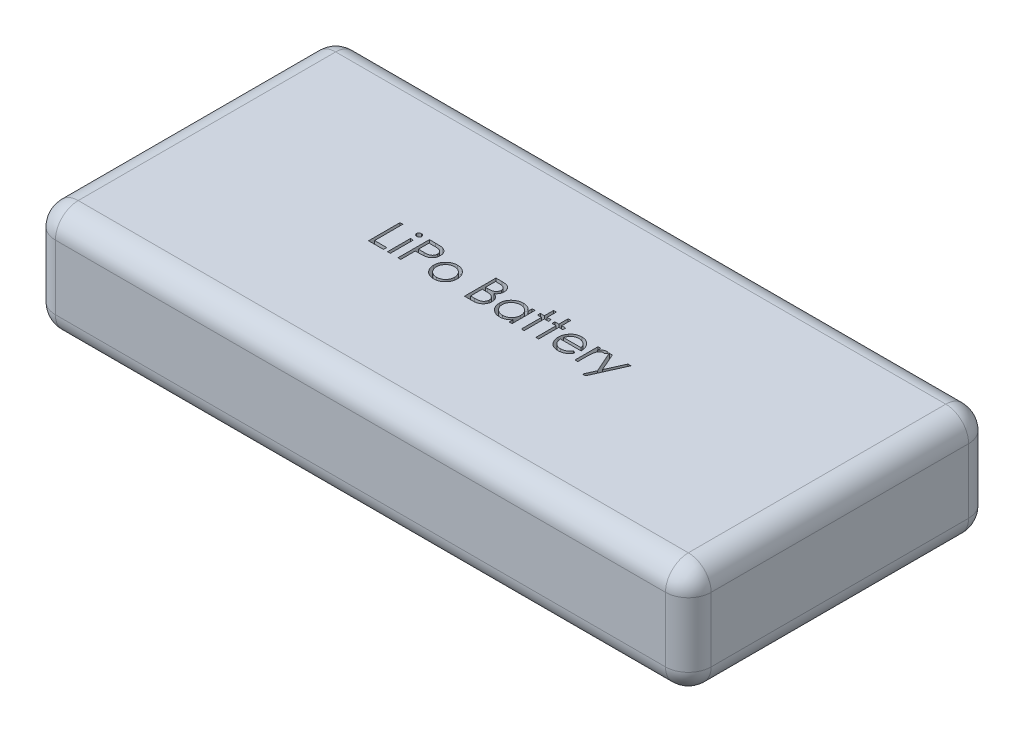
from build123d import *

# Parameters (mm, degrees)
SKETCH1_W           = 72.9742
SKETCH1_H           = 33.7312
BOSS_EXTRUDE1_DEPTH = 12.2682
SKETCH2_W           = 0.314102564
SKETCH2_H           = 2.557692308
CUT_EXTRUDE1_DEPTH  = 1.778
FILLET1_R           = 2.54


with BuildPart() as part:
    # Sketch1 → Boss-Extrude1 (new body)
    with BuildSketch(Plane(origin=(0, 0, 0), x_dir=(1, 0, 0), z_dir=(0, 1, 0))):
        with Locations((36.4871, 16.8656)):
            Rectangle(SKETCH1_W, SKETCH1_H)
    extrude(amount=BOSS_EXTRUDE1_DEPTH)

    # Sketch2 → Cut-Extrude1 (cut)
    with BuildSketch(Plane(origin=(0, 12.2682, 0), x_dir=(1, 0, 0), z_dir=(0, 1, 0))):
        Polygon((22.570507121, 18.316928385), (22.884609685, 18.316928385), (22.884609685, 15.175902744), (24.230763531, 15.175902744), (24.230763531, 14.816928385), (22.570507121, 14.816928385), align=None)
        with BuildLine():
            add(Edge.make_bspline(
                [(24.835130518, 18.45154377), (24.854621834, 18.450639617), (24.892789574, 18.448869113), (24.947982841, 18.433707636), (24.998239853, 18.408007951), (25.042817586, 18.37352827), (25.081069473, 18.332978826), (25.107850183, 18.285717858), (25.125062579, 18.234659219), (25.127141135, 18.19904413), (25.128199428, 18.180910757)],
                knots=[0, 0, 0, 0, 5.84e-05, 0.000114358, 0.000170171, 0.000226684, 0.000282761, 0.000336156, 0.000388483, 0.00044276, 0.00044276, 0.00044276, 0.00044276], degree=3))
            add(Edge.make_bspline(
                [(25.128199428, 18.180910757), (25.127117268, 18.163248104), (25.124977967, 18.128331129), (25.107863478, 18.078157657), (25.08084124, 18.031553373), (25.042842115, 17.991082663), (24.998233354, 17.956622043), (24.947984568, 17.930917304), (24.892789119, 17.915757167), (24.85462168, 17.913986478), (24.835130518, 17.913082231)],
                knots=[0, 0, 0, 0, 5.2882e-05, 0.000104542, 0.000157332, 0.000213408, 0.000269922, 0.000325735, 0.000381693, 0.000440092, 0.000440092, 0.000440092, 0.000440092], degree=3))
            add(Edge.make_bspline(
                [(24.835130518, 17.913082231), (24.815862243, 17.913951951), (24.778359063, 17.915644748), (24.72399222, 17.931214766), (24.674163731, 17.956630839), (24.629499058, 17.990857024), (24.592268865, 18.031801921), (24.56517054, 18.078129215), (24.548095578, 18.12833837), (24.545950949, 18.163250536), (24.544866095, 18.180910757)],
                knots=[0, 0, 0, 0, 5.7701e-05, 0.000112308, 0.000168121, 0.000224634, 0.000280239, 0.000333029, 0.000384689, 0.000437571, 0.000437571, 0.000437571, 0.000437571], degree=3))
            add(Edge.make_bspline(
                [(24.544866095, 18.180910757), (24.545927182, 18.199041606), (24.548011223, 18.234651739), (24.565183339, 18.285746772), (24.592043147, 18.332728274), (24.62952371, 18.373753773), (24.67415717, 18.407999208), (24.723993915, 18.433410189), (24.778358615, 18.448981529), (24.815862091, 18.450674143), (24.835130518, 18.45154377)],
                knots=[0, 0, 0, 0, 5.4277e-05, 0.000106603, 0.000159999, 0.000215605, 0.000272118, 0.000327931, 0.000382538, 0.000440239, 0.000440239, 0.000440239, 0.000440239], degree=3))
        make_face()
        with Locations((24.836532762, 16.095774539)):
            Rectangle(SKETCH2_W, SKETCH2_H)
        with BuildLine():
            Line((25.846148146, 18.316928385), (26.532546383, 18.316928385))
            add(Edge.make_bspline(
                [(26.532546383, 18.316928385), (26.57975729, 18.316876489), (26.670215482, 18.316777053), (26.799930538, 18.313762307), (26.91774027, 18.309735615), (27.023390651, 18.304153722), (27.117206749, 18.297557132), (27.198764048, 18.288305093), (27.268703605, 18.278644797), (27.310610054, 18.26882339), (27.329721864, 18.26434425)],
                knots=[0, 0, 0, 0, 0.000141628, 0.000271366, 0.00038923, 0.000495248, 0.00058876, 0.000671296, 0.000741499, 0.00080036, 0.00080036, 0.00080036, 0.00080036], degree=3))
            add(Edge.make_bspline(
                [(27.329721864, 18.26434425), (27.353915398, 18.257722301), (27.401732375, 18.244634439), (27.470633418, 18.218420715), (27.536187264, 18.18733855), (27.598618822, 18.15191461), (27.657160905, 18.110629046), (27.712686946, 18.065155428), (27.764706927, 18.01444386), (27.812928318, 17.95906312), (27.857213116, 17.89994291), (27.895342799, 17.83620068), (27.927270026, 17.768909377), (27.954653297, 17.698115806), (27.974361752, 17.623225482), (27.989208651, 17.54475877), (27.998632279, 17.46272408), (27.999534841, 17.406664212), (27.9999943, 17.378126302)],
                knots=[0, 0, 0, 0, 7.5216e-05, 0.00014866, 0.000220794, 0.000292713, 0.000363707, 0.000435434, 0.000507823, 0.000581364, 0.000655543, 0.000729131, 0.000803767, 0.000878771, 0.000956497, 0.001035702, 0.001118238, 0.001203821, 0.001203821, 0.001203821, 0.001203821], degree=3))
            add(Edge.make_bspline(
                [(27.9999943, 17.378126302), (27.999572875, 17.349348525), (27.998748329, 17.293042861), (27.988852044, 17.210670073), (27.975521852, 17.131951683), (27.9550248, 17.057062232), (27.928179127, 16.986446462), (27.896687074, 16.91902523), (27.858703544, 16.855945558), (27.815058714, 16.79697844), (27.76650712, 16.742068528), (27.713254182, 16.691613733), (27.655514889, 16.645909395), (27.593472741, 16.604853051), (27.526522892, 16.569396772), (27.455680739, 16.537639467), (27.380330522, 16.510968406), (27.328188008, 16.496938345), (27.301676992, 16.489804988)],
                knots=[0, 0, 0, 0, 8.6284e-05, 0.00016882, 0.000248587, 0.000325638, 0.000401297, 0.000474998, 0.000548586, 0.000621785, 0.0006948, 0.0007682, 0.000841564, 0.000915458, 0.000991056, 0.00106858, 0.00114819, 0.001230532, 0.001230532, 0.001230532, 0.001230532], degree=3))
            add(Edge.make_bspline(
                [(27.301676992, 16.489804988), (27.279749658, 16.485142006), (27.231694631, 16.474922812), (27.152551909, 16.463514355), (27.060406523, 16.453776755), (26.955384243, 16.446475617), (26.837579338, 16.440225249), (26.706928081, 16.435257155), (26.563174004, 16.432527301), (26.462902759, 16.432386508), (26.410551191, 16.432313)],
                knots=[0, 0, 0, 0, 6.7238e-05, 0.000147357, 0.000239727, 0.000345177, 0.000463135, 0.000593636, 0.000737393, 0.000894446, 0.000894446, 0.000894446, 0.000894446], degree=3))
            Line((26.410551191, 16.432313), (26.16025071, 16.432313))
            Line((26.16025071, 16.432313), (26.16025071, 14.816928385))
            Line((26.16025071, 14.816928385), (25.846148146, 14.816928385))
            Line((25.846148146, 14.816928385), (25.846148146, 18.316928385))
        make_face()
        with BuildLine():
            Line((26.16025071, 17.957954026), (26.16025071, 16.791287359))
            Line((26.16025071, 16.791287359), (26.773031159, 16.78357502))
            add(Edge.make_bspline(
                [(26.773031159, 16.78357502), (26.802951085, 16.783559556), (26.860710885, 16.783529704), (26.944147108, 16.787514927), (27.021556395, 16.79211546), (27.092700971, 16.798851383), (27.157612905, 16.808372641), (27.216400434, 16.817984379), (27.268607717, 16.831889741), (27.329706919, 16.850612811), (27.397790266, 16.882545426), (27.471857815, 16.928895316), (27.534628401, 16.987976025), (27.588946698, 17.054403856), (27.632052576, 17.128302985), (27.663608568, 17.207371922), (27.682149725, 17.290799772), (27.684635919, 17.34788791), (27.685891736, 17.376724058)],
                knots=[0, 0, 0, 0, 8.9746e-05, 0.000173253, 0.000250533, 0.00032239, 0.000387534, 0.00044736, 0.000500926, 0.000549486, 0.000638903, 0.000725641, 0.000810488, 0.000896226, 0.000982324, 0.00106604, 0.001150757, 0.001237226, 0.001237226, 0.001237226, 0.001237226], degree=3))
            add(Edge.make_bspline(
                [(27.685891736, 17.376724058), (27.684629089, 17.404862572), (27.682119105, 17.460798454), (27.663463241, 17.542777214), (27.632113927, 17.621012919), (27.588657333, 17.693986004), (27.535916203, 17.760174808), (27.47461686, 17.817671935), (27.404903599, 17.863893638), (27.340055368, 17.893726919), (27.282454181, 17.911942195), (27.232422222, 17.924687035), (27.175931547, 17.934862642), (27.112963768, 17.943102144), (27.044006934, 17.950155606), (26.968468619, 17.954941583), (26.886634976, 17.957743039), (26.829824405, 17.957881994), (26.800374909, 17.957954026)],
                knots=[0, 0, 0, 0, 8.4371e-05, 0.000167719, 0.000250783, 0.000336277, 0.000421575, 0.000503926, 0.000587348, 0.000671427, 0.000717102, 0.000768457, 0.000826213, 0.000889178, 0.000958942, 0.001034123, 0.001116202, 0.001204546, 0.001204546, 0.001204546, 0.001204546], degree=3))
            Line((26.800374909, 17.957954026), (26.16025071, 17.957954026))
        make_face(mode=Mode.SUBTRACT)
        with BuildLine():
            add(Edge.make_bspline(
                [(29.863576031, 17.419492488), (29.911567304, 17.418470596), (30.005666461, 17.416466918), (30.143474347, 17.395051952), (30.275019483, 17.362304588), (30.400805675, 17.317033026), (30.519221971, 17.256351075), (30.631993215, 17.183941784), (30.738810224, 17.09815919), (30.802833253, 17.031801122), (30.835330839, 16.998118289)],
                knots=[0, 0, 0, 0, 0.000143868, 0.000282091, 0.000417278, 0.000550139, 0.000682145, 0.000815559, 0.000951665, 0.001091969, 0.001091969, 0.001091969, 0.001091969], degree=3))
            add(Edge.make_bspline(
                [(30.835330839, 16.998118289), (30.863312793, 16.965904303), (30.918735173, 16.902099761), (30.989800892, 16.798644148), (31.051022452, 16.691504047), (31.100085413, 16.579256721), (31.138770436, 16.462882049), (31.166236133, 16.341980038), (31.182573068, 16.216817691), (31.184776035, 16.131813853), (31.185891736, 16.088763321)],
                knots=[0, 0, 0, 0, 0.000127922, 0.000253368, 0.000375813, 0.000497617, 0.000620225, 0.000743195, 0.000869033, 0.000998161, 0.000998161, 0.000998161, 0.000998161], degree=3))
            add(Edge.make_bspline(
                [(31.185891736, 16.088763321), (31.184910399, 16.045463263), (31.18297123, 15.95990033), (31.164627614, 15.833880964), (31.136096528, 15.711686141), (31.09526469, 15.593827448), (31.042906581, 15.47994462), (30.979015893, 15.370535071), (30.903144276, 15.265382938), (30.817140279, 15.165381099), (30.722088403, 15.073214885), (30.618972255, 14.992886615), (30.509818221, 14.924065091), (30.393174868, 14.868628675), (30.270107381, 14.824918975), (30.140350313, 14.794218958), (30.004105242, 14.775657275), (29.911078021, 14.773273701), (29.863576031, 14.77205659)],
                knots=[0, 0, 0, 0, 0.000129829, 0.000256548, 0.000381202, 0.000505812, 0.000630045, 0.000756669, 0.000885282, 0.001018518, 0.001151902, 0.001281775, 0.001409974, 0.001538236, 0.001668405, 0.001801048, 0.001937587, 0.002080055, 0.002080055, 0.002080055, 0.002080055], degree=3))
            add(Edge.make_bspline(
                [(29.863576031, 14.77205659), (29.815841311, 14.773277786), (29.722350452, 14.775669561), (29.58562447, 14.794146844), (29.455634851, 14.824904826), (29.332406252, 14.868772319), (29.215261405, 14.924066863), (29.105474908, 14.992678552), (29.002274993, 15.073238707), (28.907203008, 15.165374644), (28.821204403, 15.265384601), (28.745331395, 15.370534639), (28.681441069, 15.479944733), (28.629082865, 15.593827418), (28.588251052, 15.711686149), (28.559719959, 15.833880962), (28.541376345, 15.95990033), (28.539437176, 16.045463263), (28.538455839, 16.088763321)],
                knots=[0, 0, 0, 0, 0.000143168, 0.000280402, 0.000413045, 0.000543214, 0.000672108, 0.000800903, 0.000930775, 0.00106416, 0.001197395, 0.001326009, 0.001452632, 0.001576866, 0.001701476, 0.00182613, 0.001952849, 0.002082678, 0.002082678, 0.002082678, 0.002082678], degree=3))
            add(Edge.make_bspline(
                [(28.538455839, 16.088763321), (28.539579149, 16.131579867), (28.54180311, 16.216349269), (28.558123619, 16.34127633), (28.585482176, 16.461973719), (28.624213572, 16.577899195), (28.673728763, 16.689654631), (28.734090051, 16.797059462), (28.805880684, 16.900047262), (28.861082635, 16.963769342), (28.889016736, 16.996014923)],
                knots=[0, 0, 0, 0, 0.000128428, 0.000254265, 0.000377235, 0.000499178, 0.000620341, 0.000743397, 0.000868267, 0.000996189, 0.000996189, 0.000996189, 0.000996189], degree=3))
            add(Edge.make_bspline(
                [(28.889016736, 16.996014923), (28.921465327, 17.029989863), (28.985281191, 17.096807559), (29.092629919, 17.182340083), (29.20512374, 17.256256157), (29.324848666, 17.315732372), (29.450531524, 17.36257089), (29.582750766, 17.395136405), (29.721026282, 17.41638976), (29.815585903, 17.418447938), (29.863576031, 17.419492488)],
                knots=[0, 0, 0, 0, 0.000140798, 0.000276904, 0.000410699, 0.000543958, 0.000677061, 0.000812248, 0.000951858, 0.001095726, 0.001095726, 0.001095726, 0.001095726], degree=3))
        make_face()
        with BuildLine():
            add(Edge.make_bspline(
                [(29.862173787, 17.105389923), (29.828236176, 17.104425332), (29.761237047, 17.102521049), (29.662617463, 17.088037144), (29.567677309, 17.06508964), (29.476236464, 17.032485584), (29.388603292, 16.990386685), (29.30469389, 16.938678325), (29.22426145, 16.878045369), (29.148879386, 16.808582697), (29.079697074, 16.732703702), (29.019219098, 16.651855344), (28.967793991, 16.567348997), (28.924953832, 16.479096786), (28.893046644, 16.386204372), (28.869873622, 16.289723741), (28.855403381, 16.189458325), (28.853517003, 16.121297306), (28.852558403, 16.086659955)],
                knots=[0, 0, 0, 0, 0.000101781, 0.000200935, 0.000298373, 0.000394396, 0.000491609, 0.000589491, 0.000689611, 0.000793323, 0.000896562, 0.000997243, 0.001095722, 0.001192936, 0.001290943, 0.001389744, 0.001490285, 0.001594167, 0.001594167, 0.001594167, 0.001594167], degree=3))
            add(Edge.make_bspline(
                [(28.852558403, 16.086659955), (28.854165226, 16.041907928), (28.857354471, 15.953083523), (28.883289707, 15.8222724), (28.926675987, 15.696690548), (28.985263267, 15.577074162), (29.058669485, 15.466401884), (29.145156552, 15.3677304), (29.243796252, 15.282544588), (29.353412753, 15.211863743), (29.471767071, 15.155703987), (29.597023392, 15.115905011), (29.727664086, 15.090033319), (29.816944817, 15.087461844), (29.862173787, 15.086159154)],
                knots=[0, 0, 0, 0, 0.000134178, 0.000266319, 0.000398243, 0.00053182, 0.000664828, 0.000795487, 0.000924236, 0.001054533, 0.001185628, 0.001316003, 0.001448011, 0.001583547, 0.001583547, 0.001583547, 0.001583547], degree=3))
            add(Edge.make_bspline(
                [(29.862173787, 15.086159154), (29.907400156, 15.087469434), (29.996675752, 15.090055891), (30.127134929, 15.115774711), (30.252048901, 15.155878372), (30.370280288, 15.211800582), (30.479846892, 15.282812996), (30.579196013, 15.367249373), (30.664944624, 15.466663225), (30.738278229, 15.577220754), (30.797824972, 15.696505106), (30.841008174, 15.822295578), (30.86700576, 15.95307762), (30.870186588, 16.041905951), (30.871789172, 16.086659955)],
                knots=[0, 0, 0, 0, 0.000135536, 0.000267545, 0.000397252, 0.000528347, 0.000658644, 0.000787925, 0.000918122, 0.00105113, 0.001185017, 0.001316942, 0.001449082, 0.00158326, 0.00158326, 0.00158326, 0.00158326], degree=3))
            add(Edge.make_bspline(
                [(30.871789172, 16.086659955), (30.870830902, 16.121297513), (30.868945173, 16.189458939), (30.854470208, 16.289721392), (30.831314669, 16.386212989), (30.799343051, 16.479064992), (30.756689038, 16.567577497), (30.704272244, 16.651607224), (30.644041219, 16.73298377), (30.574024098, 16.808337411), (30.49872072, 16.878072447), (30.418255682, 16.938701837), (30.334470704, 16.990159432), (30.247092121, 17.032845673), (30.155639553, 17.064793013), (30.060832424, 17.088169644), (29.962633614, 17.102459841), (29.895874571, 17.104406983), (29.862173787, 17.105389923)],
                knots=[0, 0, 0, 0, 0.000103882, 0.000204424, 0.000303225, 0.000401232, 0.000498445, 0.000597291, 0.000697972, 0.000801684, 0.000905395, 0.001005516, 0.001103397, 0.001199979, 0.001296663, 0.00139342, 0.001492573, 0.001593654, 0.001593654, 0.001593654, 0.001593654], degree=3))
        make_face(mode=Mode.SUBTRACT)
        with BuildLine():
            Line((33.2499943, 18.316928385), (33.932886928, 18.316928385))
            add(Edge.make_bspline(
                [(33.932886928, 18.316928385), (33.966315406, 18.316752635), (34.031108117, 18.316411987), (34.125327559, 18.311128855), (34.213576369, 18.303925186), (34.295880142, 18.292495093), (34.372200844, 18.278703316), (34.442768481, 18.2620015), (34.507358654, 18.241974886), (34.58447139, 18.210128605), (34.672392051, 18.162805436), (34.767590443, 18.092876871), (34.848994683, 18.007344408), (34.919181, 17.910861753), (34.97498212, 17.804725981), (35.015351417, 17.691466792), (35.040909292, 17.57254505), (35.043537727, 17.490901872), (35.044866095, 17.449640725)],
                knots=[0, 0, 0, 0, 0.00010027, 0.000194349, 0.000283026, 0.000365821, 0.000443519, 0.000515622, 0.000583254, 0.00064614, 0.000765662, 0.000881909, 0.000998927, 0.001118415, 0.001238844, 0.00135727, 0.001478274, 0.001601912, 0.001601912, 0.001601912, 0.001601912], degree=3))
            add(Edge.make_bspline(
                [(35.044866095, 17.449640725), (35.043772876, 17.410988169), (35.041624599, 17.335032252), (35.02108184, 17.223938143), (34.988921171, 17.118186924), (34.944215922, 17.018164538), (34.886113926, 16.926130925), (34.817255607, 16.841343659), (34.734178805, 16.767392602), (34.671935565, 16.7260497), (34.640318819, 16.705049379)],
                knots=[0, 0, 0, 0, 0.000115857, 0.00022767, 0.000337672, 0.000446877, 0.000555233, 0.000663318, 0.000773539, 0.000887324, 0.000887324, 0.000887324, 0.000887324], degree=3))
            add(Edge.make_bspline(
                [(34.640318819, 16.705049379), (34.680079247, 16.68978438), (34.756150794, 16.660578655), (34.860836807, 16.608943191), (34.951031652, 16.552781081), (35.027428798, 16.491449231), (35.092766453, 16.42534042), (35.149819394, 16.353485306), (35.198500768, 16.274946548), (35.240213692, 16.190543012), (35.272762448, 16.101136544), (35.297138352, 16.007565768), (35.311105801, 15.910166213), (35.313093443, 15.843880833), (35.314096864, 15.810417968)],
                knots=[0, 0, 0, 0, 0.000127722, 0.000244363, 0.000349599, 0.000445847, 0.000537565, 0.000627901, 0.000720503, 0.000814257, 0.000909859, 0.001005428, 0.001103887, 0.001204268, 0.001204268, 0.001204268, 0.001204268], degree=3))
            add(Edge.make_bspline(
                [(35.314096864, 15.810417968), (35.313120018, 15.776251096), (35.311198046, 15.709026818), (35.297018074, 15.610271684), (35.273008967, 15.515896737), (35.239937821, 15.425291554), (35.196775506, 15.33863142), (35.144247542, 15.255818156), (35.081615979, 15.177683825), (35.01155311, 15.103360202), (34.932290964, 15.036532415), (34.846775209, 14.977016708), (34.753928889, 14.928070646), (34.655276895, 14.886954624), (34.549712579, 14.855547426), (34.437709972, 14.833574852), (34.31936567, 14.818769815), (34.238155919, 14.81755261), (34.196508723, 14.816928385)],
                knots=[0, 0, 0, 0, 0.000102481, 0.000201635, 0.000298562, 0.000394165, 0.000490425, 0.000588455, 0.000687769, 0.000790423, 0.000894381, 0.000998232, 0.001102369, 0.001208616, 0.001318415, 0.001432129, 0.001550749, 0.00167562, 0.00167562, 0.00167562, 0.00167562], degree=3))
            Line((34.196508723, 14.816928385), (33.2499943, 14.816928385))
            Line((33.2499943, 14.816928385), (33.2499943, 18.316928385))
        make_face()
        with BuildLine():
            Line((33.564096864, 17.957954026), (33.564096864, 16.836159154))
            Line((33.564096864, 16.836159154), (33.775134524, 16.836159154))
            add(Edge.make_bspline(
                [(33.775134524, 16.836159154), (33.80598332, 16.836559077), (33.865589479, 16.83733181), (33.951909376, 16.839545327), (34.032034394, 16.84574337), (34.105826227, 16.851939632), (34.173168671, 16.86201422), (34.233912532, 16.874006343), (34.289011129, 16.886689248), (34.352550675, 16.908258735), (34.424623623, 16.94013641), (34.501456727, 16.989608246), (34.569191197, 17.0485326), (34.626388385, 17.116523561), (34.673199855, 17.191389747), (34.70571357, 17.271936628), (34.727760855, 17.35615676), (34.729752386, 17.413975012), (34.730763531, 17.443330629)],
                knots=[0, 0, 0, 0, 9.2559e-05, 0.000178842, 0.000258967, 0.000333616, 0.000400942, 0.000463093, 0.000519379, 0.000570374, 0.000664201, 0.000755025, 0.000843472, 0.000932526, 0.001020669, 0.001107124, 0.001192318, 0.001280185, 0.001280185, 0.001280185, 0.001280185], degree=3))
            add(Edge.make_bspline(
                [(34.730763531, 17.443330629), (34.730237351, 17.4627564), (34.729205191, 17.500862172), (34.720751888, 17.556411526), (34.706384314, 17.608655279), (34.68793002, 17.658309389), (34.662141332, 17.703821239), (34.631777868, 17.746764435), (34.595092178, 17.785676554), (34.553334866, 17.822046052), (34.505326243, 17.85429058), (34.451094951, 17.882531343), (34.389907274, 17.90527212), (34.322794419, 17.925188272), (34.248723331, 17.939176566), (34.168548778, 17.950829954), (34.081614059, 17.956762696), (34.021468956, 17.957548058), (33.990378915, 17.957954026)],
                knots=[0, 0, 0, 0, 5.8261e-05, 0.000114285, 0.000168029, 0.000220632, 0.000272728, 0.000324483, 0.000378062, 0.000432741, 0.000490301, 0.000551137, 0.000615721, 0.000685833, 0.000760908, 0.00084162, 0.000928788, 0.00102206, 0.00102206, 0.00102206, 0.00102206], degree=3))
            Line((33.990378915, 17.957954026), (33.564096864, 17.957954026))
        make_face(mode=Mode.SUBTRACT)
        with BuildLine():
            Line((33.564096864, 16.477184795), (33.564096864, 15.175902744))
            Line((33.564096864, 15.175902744), (34.011412569, 15.175902744))
            add(Edge.make_bspline(
                [(34.011412569, 15.175902744), (34.043431495, 15.176286491), (34.105143754, 15.177026114), (34.194244984, 15.179440668), (34.276828088, 15.184932944), (34.352516223, 15.193578794), (34.422126676, 15.202957243), (34.484824379, 15.215568524), (34.541117573, 15.230017484), (34.60639188, 15.252351657), (34.679895389, 15.287048128), (34.759106245, 15.339362354), (34.829532463, 15.401685662), (34.889337722, 15.473816576), (34.938350711, 15.552247903), (34.974006166, 15.635393253), (34.995997023, 15.72187878), (34.998659192, 15.780845493), (34.9999943, 15.810417968)],
                knots=[0, 0, 0, 0, 9.6064e-05, 0.000185151, 0.000267373, 0.000344257, 0.000413665, 0.000478015, 0.000536005, 0.000587888, 0.000684801, 0.000778918, 0.000871787, 0.000965866, 0.001059062, 0.00114827, 0.001236355, 0.001324974, 0.001324974, 0.001324974, 0.001324974], degree=3))
            add(Edge.make_bspline(
                [(34.9999943, 15.810417968), (34.999718196, 15.828911309), (34.999170441, 15.865599691), (34.990909826, 15.91951551), (34.978895956, 15.971741383), (34.963364522, 16.022419124), (34.940745055, 16.0706325), (34.91433851, 16.117335059), (34.883377108, 16.162588539), (34.835132942, 16.219800792), (34.764960958, 16.285717805), (34.665254182, 16.350255308), (34.551881884, 16.402303115), (34.469654392, 16.424402591), (34.427177794, 16.435818609)],
                knots=[0, 0, 0, 0, 5.5429e-05, 0.000109963, 0.000163198, 0.000216191, 0.000268588, 0.000322593, 0.000377046, 0.000432793, 0.000546889, 0.000664343, 0.000787646, 0.000919405, 0.000919405, 0.000919405, 0.000919405], degree=3))
            add(Edge.make_bspline(
                [(34.427177794, 16.435818609), (34.410148698, 16.439273693), (34.373226105, 16.446765028), (34.313018525, 16.454672731), (34.244282656, 16.461717791), (34.166859779, 16.466928949), (34.080651938, 16.472315492), (33.985475019, 16.474410314), (33.881717704, 16.476909574), (33.809725332, 16.477090708), (33.772330037, 16.477184795)],
                knots=[0, 0, 0, 0, 5.2115e-05, 0.000112995, 0.000182062, 0.000259389, 0.000345767, 0.00044116, 0.000544948, 0.000657129, 0.000657129, 0.000657129, 0.000657129], degree=3))
            Line((33.772330037, 16.477184795), (33.564096864, 16.477184795))
        make_face(mode=Mode.SUBTRACT)
        with BuildLine():
            Line((38.544866095, 17.374620693), (38.544866095, 14.816928385))
            Line((38.544866095, 14.816928385), (38.230763531, 14.816928385))
            Line((38.230763531, 14.816928385), (38.230763531, 15.259336238))
            add(Edge.make_bspline(
                [(38.230763531, 15.259336238), (38.19534474, 15.219296644), (38.126224525, 15.141158873), (38.010783407, 15.0390767), (37.888415229, 14.954698378), (37.759713908, 14.886548463), (37.624795665, 14.835356406), (37.483959577, 14.798970247), (37.337148196, 14.775576412), (37.236895842, 14.77324039), (37.186092056, 14.77205659)],
                knots=[0, 0, 0, 0, 0.000160263, 0.000312755, 0.000460949, 0.000605216, 0.000748578, 0.000892786, 0.001041028, 0.001193333, 0.001193333, 0.001193333, 0.001193333], degree=3))
            add(Edge.make_bspline(
                [(37.186092056, 14.77205659), (37.140924103, 14.773282962), (37.051850898, 14.775701423), (36.920821821, 14.794463726), (36.794729571, 14.824594348), (36.673454998, 14.866495238), (36.557782853, 14.922076059), (36.446722756, 14.988617307), (36.340850064, 15.067858137), (36.241778525, 15.158446166), (36.150546525, 15.256841153), (36.070485252, 15.3617867), (36.003732173, 15.472829004), (35.947912092, 15.588562157), (35.904915747, 15.709877077), (35.874942113, 15.836354245), (35.856201666, 15.967844119), (35.853784206, 16.057383642), (35.852558403, 16.102785757)],
                knots=[0, 0, 0, 0, 0.000135464, 0.00026714, 0.000396211, 0.000523931, 0.000651257, 0.000780517, 0.000911767, 0.001047265, 0.00118272, 0.001313831, 0.001442491, 0.001570752, 0.001698704, 0.001827775, 0.001960146, 0.00209631, 0.00209631, 0.00209631, 0.00209631], degree=3))
            add(Edge.make_bspline(
                [(35.852558403, 16.102785757), (35.853811374, 16.14724946), (35.856288431, 16.235151804), (35.874741651, 16.364430502), (35.905772659, 16.488948762), (35.949320507, 16.608305706), (36.005162462, 16.722645756), (36.073090549, 16.832049781), (36.153109674, 16.936819178), (36.245362081, 17.034490405), (36.345296851, 17.124711019), (36.452205582, 17.203120065), (36.563428863, 17.270836914), (36.680691874, 17.32449039), (36.802258978, 17.367899494), (36.929212424, 17.397932463), (37.061024003, 17.415629784), (37.150514495, 17.418192548), (37.195907762, 17.419492488)],
                knots=[0, 0, 0, 0, 0.000133363, 0.00026365, 0.000390846, 0.000517716, 0.000644083, 0.000771912, 0.000903449, 0.001038867, 0.001174416, 0.001306792, 0.001436052, 0.00156435, 0.001692963, 0.001822716, 0.001954992, 0.002091156, 0.002091156, 0.002091156, 0.002091156], degree=3))
            add(Edge.make_bspline(
                [(37.195907762, 17.419492488), (37.248107621, 17.418054736), (37.350469081, 17.415235373), (37.50019709, 17.391772646), (37.641841568, 17.352134179), (37.77649592, 17.298216681), (37.903676606, 17.226567952), (38.02217959, 17.13618799), (38.133245074, 17.027646804), (38.197625365, 16.944276359), (38.230763531, 16.901363481)],
                knots=[0, 0, 0, 0, 0.00015654, 0.000306968, 0.000453261, 0.000596998, 0.000741098, 0.000889738, 0.001042937, 0.001205434, 0.001205434, 0.001205434, 0.001205434], degree=3))
            Line((38.230763531, 16.901363481), (38.230763531, 17.374620693))
            Line((38.230763531, 17.374620693), (38.544866095, 17.374620693))
        make_face()
        with BuildLine():
            add(Edge.make_bspline(
                [(37.200114492, 17.105389923), (37.154200154, 17.103756286), (37.063572555, 17.100531745), (36.930528552, 17.075358249), (36.803215138, 17.033473655), (36.682269064, 16.976191754), (36.569600847, 16.904163017), (36.468907177, 16.817041634), (36.379364475, 16.71720462), (36.304056211, 16.60510251), (36.242665714, 16.484924418), (36.199498682, 16.35929998), (36.171029435, 16.230495003), (36.168120914, 16.143132317), (36.166660967, 16.099280148)],
                knots=[0, 0, 0, 0, 0.000137677, 0.000271753, 0.000404561, 0.000538791, 0.000672205, 0.000804452, 0.00093703, 0.001073348, 0.00120849, 0.001340643, 0.001470999, 0.001602378, 0.001602378, 0.001602378, 0.001602378], degree=3))
            add(Edge.make_bspline(
                [(36.166660967, 16.099280148), (36.16852586, 16.055690041), (36.172248337, 15.968680685), (36.198999031, 15.839700108), (36.243878905, 15.714046066), (36.305120967, 15.592785072), (36.381807592, 15.480200972), (36.470696245, 15.378460849), (36.572646526, 15.290971261), (36.685574033, 15.217733688), (36.806182004, 15.158571167), (36.933015935, 15.117405527), (37.063691573, 15.090827747), (37.152543907, 15.08772327), (37.197310005, 15.086159154)],
                knots=[0, 0, 0, 0, 0.000130727, 0.000260941, 0.000393327, 0.000530037, 0.000667328, 0.000800955, 0.000934191, 0.001068956, 0.001203792, 0.001335934, 0.001468075, 0.001602253, 0.001602253, 0.001602253, 0.001602253], degree=3))
            add(Edge.make_bspline(
                [(37.197310005, 15.086159154), (37.242756508, 15.087819118), (37.333145094, 15.091120622), (37.466583802, 15.116401887), (37.596078765, 15.158170685), (37.719865994, 15.216069812), (37.835182125, 15.287827168), (37.938680002, 15.371834259), (38.026195971, 15.469537443), (38.10038858, 15.576913896), (38.158563997, 15.694625893), (38.200940056, 15.819960083), (38.225993962, 15.952920832), (38.229151692, 16.043784759), (38.230763531, 16.090165564)],
                knots=[0, 0, 0, 0, 0.000136278, 0.000271043, 0.000405851, 0.000543552, 0.000679927, 0.000812429, 0.000941985, 0.001072088, 0.00120284, 0.001334538, 0.001467925, 0.001607002, 0.001607002, 0.001607002, 0.001607002], degree=3))
            add(Edge.make_bspline(
                [(38.230763531, 16.090165564), (38.229803874, 16.125503395), (38.227914967, 16.195059428), (38.213484397, 16.297186946), (38.190529471, 16.394920672), (38.158183301, 16.488363361), (38.115692017, 16.576998376), (38.064444251, 16.661462137), (38.003538801, 16.741315348), (37.933956105, 16.815458419), (37.857790902, 16.883084881), (37.777196362, 16.943449122), (37.691217615, 16.993037895), (37.601300578, 17.034079166), (37.507289243, 17.066738316), (37.408418624, 17.08852601), (37.305739637, 17.103486331), (37.235693581, 17.104748712), (37.200114492, 17.105389923)],
                knots=[0, 0, 0, 0, 0.000105983, 0.000208608, 0.000308773, 0.00040678, 0.000504626, 0.000603105, 0.000702667, 0.00080535, 0.000907651, 0.001007914, 0.001106881, 0.00120477, 0.001304102, 0.001404791, 0.00150811, 0.001614764, 0.001614764, 0.001614764, 0.001614764], degree=3))
        make_face(mode=Mode.SUBTRACT)
        Polygon((39.576917377, 18.406671975), (39.891019941, 18.406671975), (39.891019941, 17.374620693), (40.33973789, 17.374620693), (40.33973789, 17.060518129), (39.891019941, 17.060518129), (39.891019941, 14.816928385), (39.576917377, 14.816928385), (39.576917377, 17.060518129), (39.128199428, 17.060518129), (39.128199428, 17.374620693), (39.576917377, 17.374620693), align=None)
        Polygon((41.192301992, 18.406671975), (41.506404556, 18.406671975), (41.506404556, 17.374620693), (41.955122505, 17.374620693), (41.955122505, 17.060518129), (41.506404556, 17.060518129), (41.506404556, 14.816928385), (41.192301992, 14.816928385), (41.192301992, 17.060518129), (40.743584044, 17.060518129), (40.743584044, 17.374620693), (41.192301992, 17.374620693), align=None)
        with BuildLine():
            Line((44.592742697, 15.624620693), (44.871789172, 15.478086238))
            add(Edge.make_bspline(
                [(44.871789172, 15.478086238), (44.849552577, 15.438642906), (44.806288968, 15.361901803), (44.73188822, 15.256469943), (44.653896148, 15.161622227), (44.56879218, 15.079892573), (44.479122501, 15.008641188), (44.384389846, 14.946303363), (44.284101028, 14.893184843), (44.178251303, 14.848432315), (44.065951752, 14.814022821), (43.946930236, 14.7897186), (43.82095874, 14.774695331), (43.734612561, 14.77295019), (43.690398947, 14.77205659)],
                knots=[0, 0, 0, 0, 0.000135759, 0.000264133, 0.000386579, 0.000503597, 0.000617365, 0.000729763, 0.000843304, 0.000957371, 0.001074023, 0.001195027, 0.001321389, 0.001453992, 0.001453992, 0.001453992, 0.001453992], degree=3))
            add(Edge.make_bspline(
                [(43.690398947, 14.77205659), (43.64125697, 14.773203765), (43.545395208, 14.775441572), (43.405855461, 14.794734037), (43.274476043, 14.826206395), (43.151264339, 14.870171937), (43.036522087, 14.927599261), (42.930021232, 14.997558743), (42.831201706, 15.079690997), (42.743177497, 15.174707441), (42.663933614, 15.276389398), (42.594007794, 15.382345283), (42.535550363, 15.492308507), (42.487997753, 15.605579031), (42.449592888, 15.721442925), (42.422826184, 15.840954392), (42.407396436, 15.963789977), (42.405031991, 16.046887312), (42.403840454, 16.088763321)],
                knots=[0, 0, 0, 0, 0.000147371, 0.000287478, 0.000421649, 0.000552053, 0.000679042, 0.000805636, 0.000933558, 0.00106351, 0.001193382, 0.001319977, 0.001443869, 0.001566405, 0.001688128, 0.001809576, 0.001933238, 0.002058864, 0.002058864, 0.002058864, 0.002058864], degree=3))
            add(Edge.make_bspline(
                [(42.403840454, 16.088763321), (42.404899595, 16.128058151), (42.406998673, 16.205935316), (42.420229461, 16.321200861), (42.443677754, 16.433229313), (42.475854078, 16.542113761), (42.517405324, 16.647671895), (42.568237543, 16.749967959), (42.628429921, 16.848893098), (42.674902595, 16.911296232), (42.698311608, 16.942729667)],
                knots=[0, 0, 0, 0, 0.000117891, 0.000233644, 0.000347498, 0.000460856, 0.000573868, 0.000687374, 0.000803169, 0.000920699, 0.000920699, 0.000920699, 0.000920699], degree=3))
            add(Edge.make_bspline(
                [(42.698311608, 16.942729667), (42.730019291, 16.980598537), (42.792430237, 17.055136688), (42.897986592, 17.153075013), (43.012286789, 17.235118789), (43.133898415, 17.303125925), (43.264234889, 17.354799572), (43.40154418, 17.393307154), (43.547389766, 17.414885165), (43.647094987, 17.417932999), (43.698111287, 17.419492488)],
                knots=[0, 0, 0, 0, 0.000148071, 0.000291452, 0.00043058, 0.000569298, 0.000708346, 0.00085021, 0.000996268, 0.001149307, 0.001149307, 0.001149307, 0.001149307], degree=3))
            add(Edge.make_bspline(
                [(43.698111287, 17.419492488), (43.750558893, 17.418138439), (43.853449138, 17.415482103), (44.00348126, 17.39085577), (44.145441976, 17.351803215), (44.27927448, 17.296649425), (44.404992341, 17.225489873), (44.521778391, 17.137348032), (44.631629903, 17.034929944), (44.695538482, 16.956166735), (44.728059204, 16.916087039)],
                knots=[0, 0, 0, 0, 0.000157241, 0.00030847, 0.000454763, 0.000598116, 0.000741606, 0.000886879, 0.001036172, 0.001190853, 0.001190853, 0.001190853, 0.001190853], degree=3))
            add(Edge.make_bspline(
                [(44.728059204, 16.916087039), (44.750186142, 16.885883457), (44.794292735, 16.825677339), (44.849539835, 16.727506182), (44.89749723, 16.624795587), (44.935830191, 16.51588529), (44.966869693, 16.40206571), (44.989326511, 16.282523165), (45.00249613, 16.157293254), (45.005084827, 16.071966698), (45.006404556, 16.028466847)],
                knots=[0, 0, 0, 0, 0.000112234, 0.000223721, 0.000337279, 0.000451932, 0.000569628, 0.000690912, 0.000816421, 0.00094695, 0.00094695, 0.00094695, 0.00094695], degree=3))
            Line((45.006404556, 16.028466847), (42.717943018, 16.028466847))
            add(Edge.make_bspline(
                [(42.717943018, 16.028466847), (42.719482624, 15.994766382), (42.722510198, 15.928495779), (42.736625342, 15.831524995), (42.758874115, 15.739151653), (42.790143178, 15.652068611), (42.828010023, 15.569138484), (42.87439574, 15.490976447), (42.929735294, 15.417938517), (42.991460993, 15.349371379), (43.060168089, 15.288310618), (43.132450836, 15.233658842), (43.209344401, 15.187853245), (43.290242484, 15.150673355), (43.37501427, 15.121567039), (43.463686465, 15.101699219), (43.556084581, 15.088392112), (43.619070315, 15.086912446), (43.651136127, 15.086159154)],
                knots=[0, 0, 0, 0, 0.000101159, 0.000198924, 0.000293472, 0.000385722, 0.000476069, 0.000566611, 0.000657757, 0.000750573, 0.000842919, 0.000933083, 0.001022062, 0.001110842, 0.001199752, 0.001290403, 0.001383113, 0.001479259, 0.001479259, 0.001479259, 0.001479259], degree=3))
            add(Edge.make_bspline(
                [(43.651136127, 15.086159154), (43.682487275, 15.086767211), (43.744693966, 15.087973712), (43.837334823, 15.099705623), (43.92847435, 15.118675898), (44.017735334, 15.144565889), (44.103306179, 15.176142741), (44.18255173, 15.214245598), (44.255431945, 15.256395345), (44.323548912, 15.30460502), (44.389619905, 15.363613207), (44.455162391, 15.437248928), (44.525439045, 15.524336456), (44.569428638, 15.589882122), (44.592742697, 15.624620693)],
                knots=[0, 0, 0, 0, 9.4016e-05, 0.000186545, 0.000279636, 0.000373054, 0.000465125, 0.000552934, 0.000636508, 0.000717442, 0.000802858, 0.000901616, 0.001012865, 0.001138311, 0.001138311, 0.001138311, 0.001138311], degree=3))
        make_face()
        with BuildLine():
            add(Edge.make_bspline(
                [(44.692301992, 16.342569411), (44.680805368, 16.384232284), (44.658678066, 16.464419905), (44.612441702, 16.575460795), (44.560370161, 16.674148696), (44.49874843, 16.759728329), (44.428929704, 16.835731842), (44.348284522, 16.902150428), (44.257848628, 16.961567879), (44.158089487, 17.011720378), (44.052447702, 17.054410237), (43.94184151, 17.083035353), (43.828983722, 17.102644895), (43.752649436, 17.104471003), (43.714237089, 17.105389923)],
                knots=[0, 0, 0, 0, 0.000129543, 0.000249328, 0.000360065, 0.000463575, 0.000564789, 0.000668832, 0.000776175, 0.000888744, 0.001003316, 0.001117263, 0.001230914, 0.001346035, 0.001346035, 0.001346035, 0.001346035], degree=3))
            add(Edge.make_bspline(
                [(43.714237089, 17.105389923), (43.68288765, 17.104778252), (43.620916401, 17.103569106), (43.529615333, 17.092098977), (43.441935634, 17.073139132), (43.357230346, 17.047174175), (43.276609478, 17.012565573), (43.19841471, 16.971982346), (43.124634313, 16.922440762), (43.078493018, 16.884681907), (43.055182601, 16.86560627)],
                knots=[0, 0, 0, 0, 9.4016e-05, 0.000185849, 0.000275511, 0.000362884, 0.000451173, 0.00053836, 0.000626838, 0.000717174, 0.000717174, 0.000717174, 0.000717174], degree=3))
            add(Edge.make_bspline(
                [(43.055182601, 16.86560627), (43.038489319, 16.850511954), (43.004706185, 16.819964738), (42.959565664, 16.767335531), (42.916345191, 16.710583969), (42.877011538, 16.647538845), (42.840933952, 16.578918066), (42.807173975, 16.50530043), (42.776787563, 16.4261273), (42.759691452, 16.370954861), (42.750895742, 16.342569411)],
                knots=[0, 0, 0, 0, 6.7454e-05, 0.00013651, 0.000207604, 0.000281328, 0.000359112, 0.000440057, 0.000524171, 0.000613305, 0.000613305, 0.000613305, 0.000613305], degree=3))
            Line((42.750895742, 16.342569411), (44.692301992, 16.342569411))
        make_face(mode=Mode.SUBTRACT)
        with BuildLine():
            Line((45.544866095, 17.374620693), (45.858968659, 17.374620693))
            Line((45.858968659, 17.374620693), (45.858968659, 16.998118289))
            add(Edge.make_bspline(
                [(45.858968659, 16.998118289), (45.882157418, 17.033174117), (45.926505739, 17.100218116), (46.000218668, 17.188887417), (46.075721999, 17.262302464), (46.153377187, 17.320805983), (46.233755287, 17.364619102), (46.315092238, 17.396712137), (46.398667708, 17.415689452), (46.454829632, 17.418223111), (46.482967056, 17.419492488)],
                knots=[0, 0, 0, 0, 0.000126023, 0.000241017, 0.000345147, 0.000441342, 0.00053171, 0.000618946, 0.000702978, 0.000787349, 0.000787349, 0.000787349, 0.000787349], degree=3))
            add(Edge.make_bspline(
                [(46.482967056, 17.419492488), (46.504793383, 17.418301961), (46.549702468, 17.415852375), (46.617685058, 17.39864155), (46.68772851, 17.371163528), (46.732870897, 17.345323305), (46.756404556, 17.331852263)],
                knots=[0, 0, 0, 0, 6.5445e-05, 0.000134658, 0.00020926, 0.000290509, 0.000290509, 0.000290509, 0.000290509], degree=3))
            Line((46.756404556, 17.331852263), (46.583928595, 17.059817007))
            add(Edge.make_bspline(
                [(46.583928595, 17.059817007), (46.568819574, 17.066557273), (46.540139759, 17.079351588), (46.498185193, 17.094493598), (46.459503856, 17.103409514), (46.434860298, 17.104760232), (46.423371704, 17.105389923)],
                knots=[0, 0, 0, 0, 4.9621e-05, 9.4191e-05, 0.00013366, 0.000168129, 0.000168129, 0.000168129, 0.000168129], degree=3))
            add(Edge.make_bspline(
                [(46.423371704, 17.105389923), (46.39816597, 17.103709886), (46.34675358, 17.100283097), (46.271269081, 17.073344289), (46.198021876, 17.029819049), (46.139850213, 16.981547937), (46.09480796, 16.93500014), (46.062667735, 16.894351737), (46.033184988, 16.848773106), (46.005014767, 16.799043422), (45.979348473, 16.744313576), (45.955393804, 16.685130362), (45.933734941, 16.621425234), (45.921384697, 16.577042713), (45.915058403, 16.554308193)],
                knots=[0, 0, 0, 0, 7.549e-05, 0.000153978, 0.000237553, 0.000330197, 0.000379784, 0.000431685, 0.000485357, 0.000542493, 0.000603021, 0.000666557, 0.00073396, 0.000804745, 0.000804745, 0.000804745, 0.000804745], degree=3))
            add(Edge.make_bspline(
                [(45.915058403, 16.554308193), (45.910326009, 16.534031019), (45.899844118, 16.48911862), (45.88965258, 16.413770096), (45.879583062, 16.324746437), (45.872486443, 16.221799844), (45.865908401, 16.1051874), (45.862198319, 15.974731455), (45.859095178, 15.830298103), (45.859012112, 15.72932375), (45.858968659, 15.676503705)],
                knots=[0, 0, 0, 0, 6.2435e-05, 0.000138289, 0.000227871, 0.000331224, 0.000447781, 0.000578258, 0.000722716, 0.000881171, 0.000881171, 0.000881171, 0.000881171], degree=3))
            Line((45.858968659, 15.676503705), (45.858968659, 14.816928385))
            Line((45.858968659, 14.816928385), (45.544866095, 14.816928385))
            Line((45.544866095, 14.816928385), (45.544866095, 17.374620693))
        make_face()
        Polygon((46.801276351, 17.374620693), (47.139918178, 17.374620693), (48.005803595, 15.415686398), (48.885010326, 17.374620693), (49.224353274, 17.374620693), (47.653840454, 13.874620693), (47.314497505, 13.874620693), (47.835430999, 15.034977263), align=None)
    extrude(amount=-CUT_EXTRUDE1_DEPTH, mode=Mode.SUBTRACT)

    # Fillet1
    fillet1_edges = [part.edges().sort_by_distance(p)[0] for p in [
        (72.9742, 12.2682, -16.8656),
        (36.4871, 12.2682, -33.7312),
        (0, 12.2682, -16.8656),
        (36.4871, 0, -33.7312),
        (72.9742, 0, -16.8656),
        (36.4871, 0, 0),
        (0, 0, -16.8656),
        (0, 6.1341, -33.7312),
        (72.9742, 6.1341, -33.7312),
        (72.9742, 6.1341, 0),
        (0, 6.1341, 0),
        (36.4871, 12.2682, 0),
    ]]
    fillet(fillet1_edges, radius=FILLET1_R)


solid = part.part
